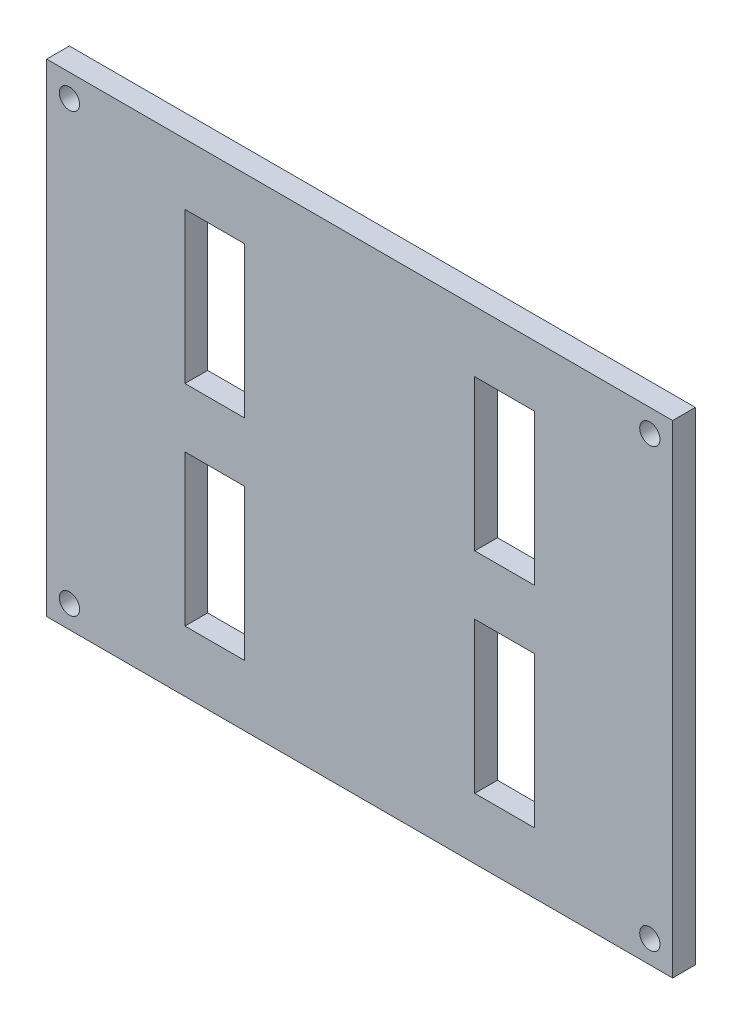
from build123d import *

# Parameters (mm, degrees)
SKETCH1_W           = 100
SKETCH1_H           = 80
BOSS_EXTRUDE1_DEPTH = 3.175
SKETCH3_W           = 100.17
SKETCH3_H           = 80.17
SKETCH3_W_2         = 87.47
SKETCH3_H_2         = 67.47
CUT_EXTRUDE2_DEPTH  = 10
SKETCH4_R           = 1.415
CUT_EXTRUDE3_DEPTH  = 10
SKETCH2_W           = 8.33
SKETCH2_H           = 21.08
CUT_EXTRUDE4_DEPTH  = 10


with BuildPart() as part:
    # Sketch1 → Boss-Extrude1 (new body)
    with BuildSketch(Plane.XY):
        Rectangle(SKETCH1_W, SKETCH1_H)
    extrude(amount=BOSS_EXTRUDE1_DEPTH)

    # Sketch3 → Cut-Extrude2 (cut)
    with BuildSketch(Plane.XY.offset(3.175)):
        Rectangle(SKETCH3_W, SKETCH3_H)
        Rectangle(SKETCH3_W_2, SKETCH3_H_2, mode=Mode.SUBTRACT)
    extrude(amount=-CUT_EXTRUDE2_DEPTH, mode=Mode.SUBTRACT)

    # Sketch4 → Cut-Extrude3 (cut)
    with BuildSketch(Plane.XY.offset(3.175)):
        with Locations((-40.553019485, 30.553019485)):
            Circle(SKETCH4_R)
        with Locations((40.553019485, 30.553019485)):
            Circle(SKETCH4_R)
        with Locations((40.553019485, -30.553019485)):
            Circle(SKETCH4_R)
        with Locations((-40.553019485, -30.553019485)):
            Circle(SKETCH4_R)
    extrude(amount=-CUT_EXTRUDE3_DEPTH, mode=Mode.SUBTRACT)

    # Sketch2 → Cut-Extrude4 (cut)
    with BuildSketch(Plane.XY.offset(3.175)):
        with Locations((-20.25, 14.675)):
            Rectangle(SKETCH2_W, SKETCH2_H)
        with Locations((20.25, 14.675)):
            Rectangle(SKETCH2_W, SKETCH2_H)
        with Locations((-20.25, -14.675)):
            Rectangle(SKETCH2_W, SKETCH2_H)
        with Locations((20.25, -14.675)):
            Rectangle(SKETCH2_W, SKETCH2_H)
    extrude(amount=-CUT_EXTRUDE4_DEPTH, mode=Mode.SUBTRACT)


solid = part.part
